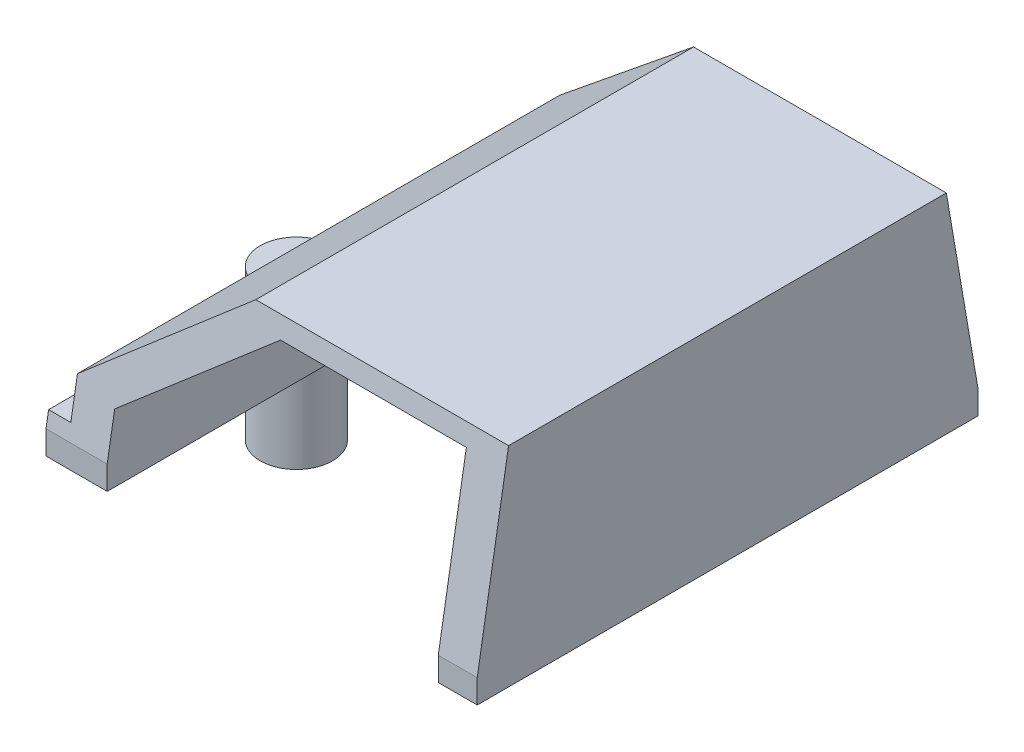
from build123d import *

# Parameters (mm, degrees)
SKETCH1_R           = 1.651
SKETCH1_W           = 20.32
SKETCH1_H           = 22.86
BOSS_EXTRUDE1_DEPTH = 9.53869225
SKETCH2_R           = 1.651
BOSS_EXTRUDE2_DEPTH = 5.08
CUT_EXTRUDE8_DEPTH  = 23.86
CUT_EXTRUDE17_DEPTH = 22.971
CUT_EXTRUDE19_DEPTH = 23.86
SKETCH24_W          = 0.635
SKETCH24_H          = 9.53869225
CUT_EXTRUDE21_DEPTH = 23.86
CUT_EXTRUDE22_DEPTH = 23.86
SKETCH31_W          = 15.113
SKETCH31_H          = 1.081615655
CUT_EXTRUDE23_DEPTH = 23.86
CUT_EXTRUDE24_DEPTH = 23.86


with BuildPart() as part:
    # Sketch1 → Boss-Extrude1 (new body)
    with BuildSketch(Plane(origin=(0, 0, -0.183030965), x_dir=(1, 0, 0), z_dir=(0, 1, 0))):
        with Locations((-13.789144221, -20.003468165)):
            Circle(SKETCH1_R)
        with Locations((-3.629144221, -20.003468165)):
            Rectangle(SKETCH1_W, SKETCH1_H)
    extrude(amount=BOSS_EXTRUDE1_DEPTH)

    # Sketch9 → Cut-Extrude8 (cut, through all)
    with BuildSketch(Plane.XY.offset(31.2504372)):
        Polygon((-12.773144221, 1.778), (-15.440144221, 1.778), (-15.440144221, 9.53869225), (-7.226565611, 9.53869225), (-12.773144221, 3.556), align=None)
    extrude(amount=-CUT_EXTRUDE8_DEPTH, mode=Mode.SUBTRACT)

    # Sketch23 → Cut-Extrude17 (cut, through all)
    with BuildSketch(Plane(origin=(6.530855779, 0, 0), x_dir=(0, 0, -1), z_dir=(1, 0, 0))):
        Polygon((-31.2504372, 9.53869225), (-31.2504372, 1.081615655), (-29.818315346, 9.53869225), align=None)
        Polygon((-9.835623726, 9.53869225), (-8.3904372, 1.081615655), (-8.3904372, 9.53869225), align=None)
    extrude(amount=-CUT_EXTRUDE17_DEPTH, mode=Mode.SUBTRACT)

    # Sketch26 → Cut-Extrude19 (cut, through all)
    with BuildSketch(Plane.XY.offset(31.2504372)):
        Polygon((-12.773144221, 3.556), (-6.64437908, 9.53869225), (-7.226565611, 9.53869225), align=None)
    extrude(amount=-CUT_EXTRUDE19_DEPTH, mode=Mode.SUBTRACT)

    # Sketch24 → Cut-Extrude21 (cut, through all)
    with BuildSketch(Plane.XY.offset(31.2504372)):
        with Locations((6.213355779, 4.769346125)):
            Rectangle(SKETCH24_W, SKETCH24_H)
    extrude(amount=-CUT_EXTRUDE21_DEPTH, mode=Mode.SUBTRACT)

    # Sketch28 → Cut-Extrude22 (cut, through all)
    with BuildSketch(Plane.XY.offset(31.2504372)):
        Polygon((-6.64437908, 9.53869225), (-5.644433666, 9.53869225), (-12.773144221, 3.556), align=None)
    extrude(amount=-CUT_EXTRUDE22_DEPTH, mode=Mode.SUBTRACT)

    # Sketch31 → Cut-Extrude23 (cut, through all)
    with BuildSketch(Plane.XY.offset(31.2504372)):
        Polygon((-10.995144221, 1.778), (-10.995144221, 1.081615655), (4.117855779, 1.081615655), (4.117855779, 7.76069225), (-5.430907705, 7.76069225), (-8.245028619, 5.398972097), (-10.995144221, 3.090967701), align=None)
        with Locations((-3.438644221, 0.540807828)):
            Rectangle(SKETCH31_W, SKETCH31_H)
    extrude(amount=-CUT_EXTRUDE23_DEPTH, mode=Mode.SUBTRACT)

    # Sketch33 → Cut-Extrude24 (cut, through all)
    with BuildSketch(Plane.XY.offset(31.2504372)):
        Polygon((-4.363878434, 8.656184878), (-5.430907705, 7.76069225), (4.117855779, 7.76069225), (4.117855779, 8.656184878), align=None)
    extrude(amount=-CUT_EXTRUDE24_DEPTH, mode=Mode.SUBTRACT)


with BuildPart() as body_2:
    # Sketch2 → Boss-Extrude2 (new body)
    with BuildSketch(Plane(origin=(0, 0, 0), x_dir=(1, 0, 0), z_dir=(0, 1, 0))):
        with Locations((-13.789144221, -19.8204372)):
            Circle(SKETCH2_R)
    extrude(amount=-BOSS_EXTRUDE2_DEPTH)


solid = Compound([part.part, body_2.part])
